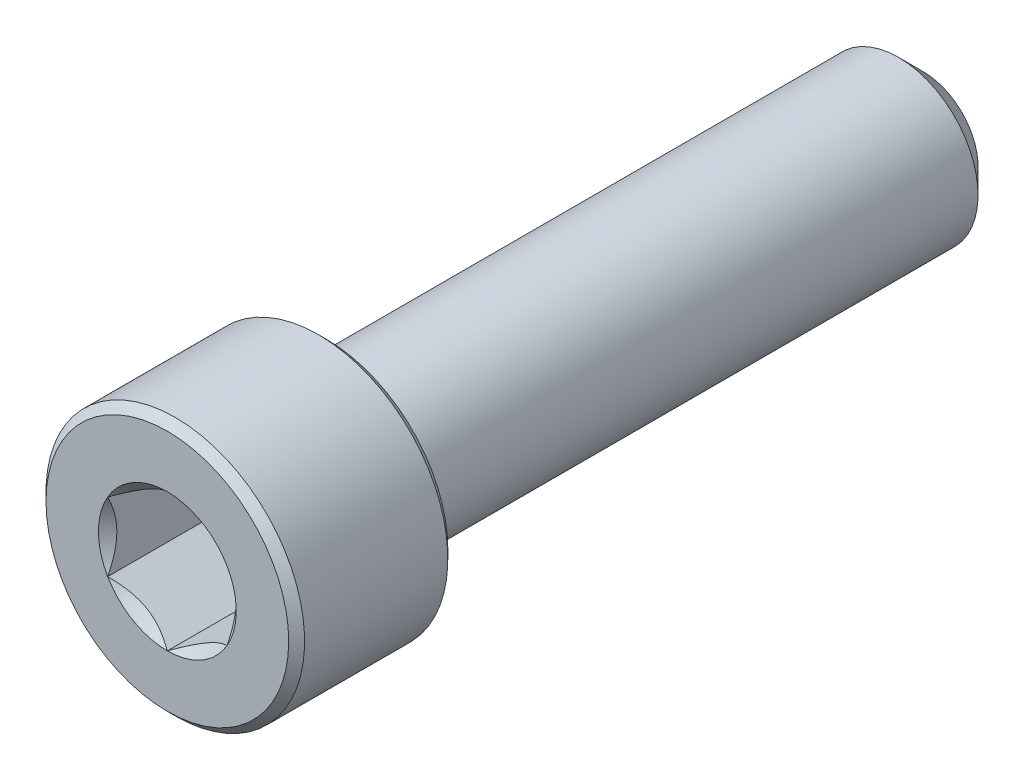
from build123d import *

# Parameters (mm, degrees)
CUT_EXTRUDE1_DEPTH = 7


with BuildPart() as part:
    # Sketch2 → Revolve1 (revolve)
    with BuildSketch(Plane(origin=(0, 0, 0), x_dir=(0, 0, -1), z_dir=(1, 0, 0))):
        Polygon((-19, 0), (-19, 6.1), (-18.6, 6.5), (-11.4, 6.5), (-11, 6.1), (-11, 4), (17.75, 4), (19, 2.75), (19, 0), align=None)
    revolve(axis=Axis((0, 0, -19), (0, 0, 1)))

    # Sketch3 → Cut-Extrude1 (cut)
    with BuildSketch(Plane.XY.offset(19)):
        Polygon((3, -1.732050808), (3, 1.732050808), (0, 3.464101615), (-3, 1.732050808), (-3, -1.732050808), (0, -3.464101615), align=None)
    extrude(amount=-CUT_EXTRUDE1_DEPTH, mode=Mode.SUBTRACT)

    # Cut-Extrude2 cone 1 section (through the dimple's axis) → Cut-Extrude2 (revolve, cut)
    with BuildSketch(Plane(origin=(0, 0, 19), x_dir=(0, -1, 0), z_dir=(1, 0, 0))):
        Polygon((0, 0), (3.464101615, 0), (0, 3.464101615), align=None)
    revolve(axis=Axis((0, 0, 19), (0, 0, -1)), mode=Mode.SUBTRACT)


solid = part.part
